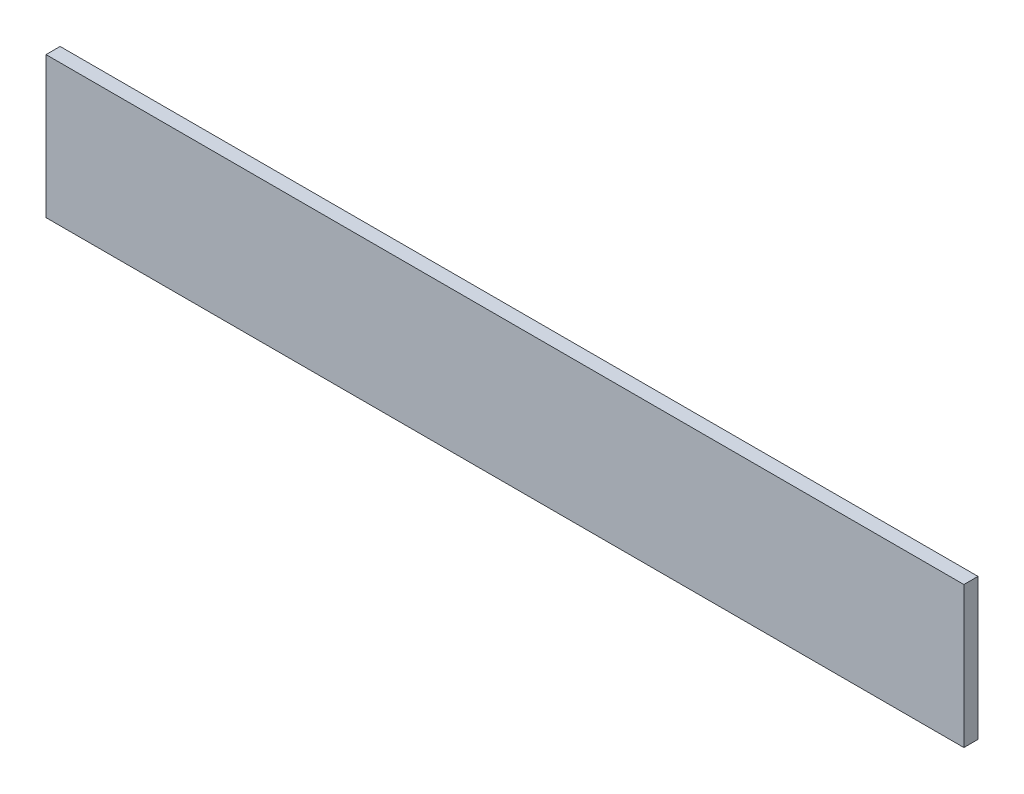
from build123d import *

# Parameters (mm, degrees)
SKETCH_1_W      = 130
SKETCH_1_H      = 20
EXTRUDE_1_DEPTH = 2


with BuildPart() as part:
    # Эскиз1 → Бобышка-Вытянуть1 (new body)
    with BuildSketch(Plane.XY):
        with Locations((65, -10)):
            Rectangle(SKETCH_1_W, SKETCH_1_H)
    extrude(amount=EXTRUDE_1_DEPTH)


solid = part.part
